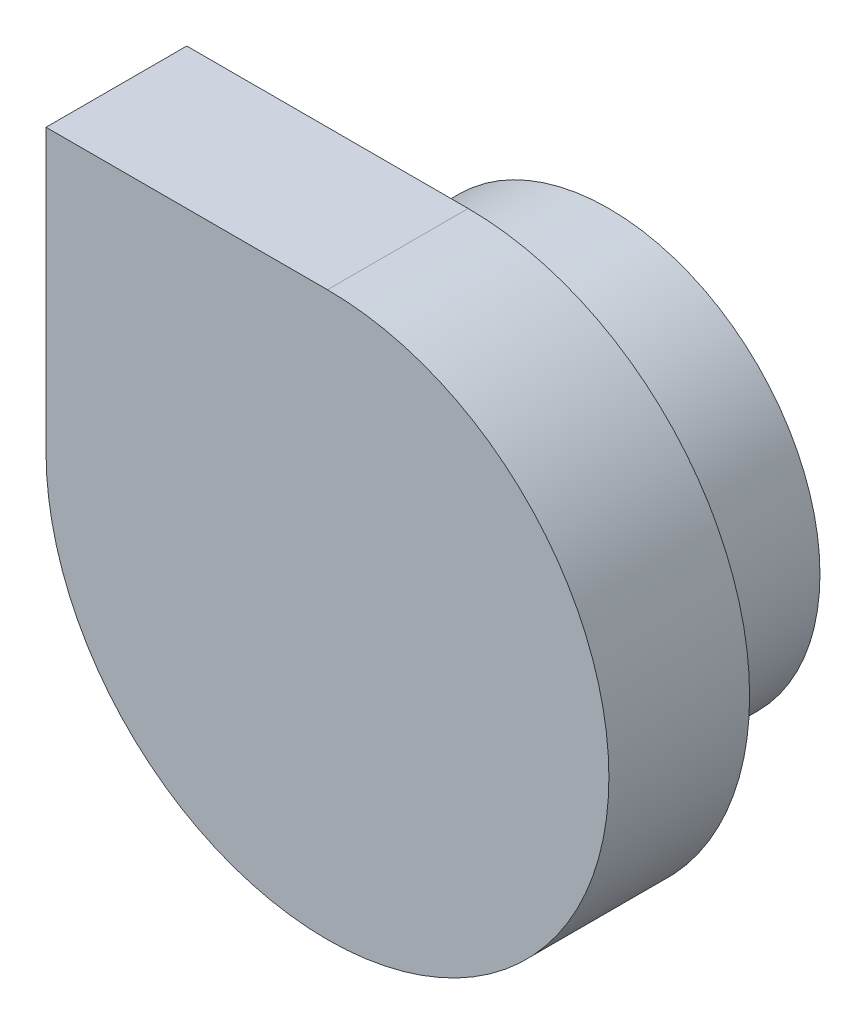
from build123d import *

# Parameters (mm, degrees)
BOSS_EXTRU_1_DEPTH = 50
ESQUISSE2_R        = 75
ESQUISSE2_R_2      = 50
BOSS_EXTRU_2_DEPTH = 50


with BuildPart() as part:
    # Esquisse1 → Boss.-Extru.1 (new body)
    with BuildSketch(Plane.XY):
        with BuildLine():
            Line((-100, 0), (-100, 100))
            Line((-100, 100), (0, 100))
            ThreePointArc((0, 100), (70.710678119, -70.710678119), (-100, 0))
        make_face()
    extrude(amount=-BOSS_EXTRU_1_DEPTH)

    # Esquisse2 → Boss.-Extru.2 (add)
    with BuildSketch(Plane(origin=(0, 0, -50), x_dir=(-1, 0, 0), z_dir=(0, 0, -1))):
        with Locations(Location((0, 0, 0), (0, 0, 180))):  # turned: the seam where the file's is
            Circle(ESQUISSE2_R)
        Circle(ESQUISSE2_R_2, mode=Mode.SUBTRACT)
    extrude(amount=BOSS_EXTRU_2_DEPTH)


solid = part.part
